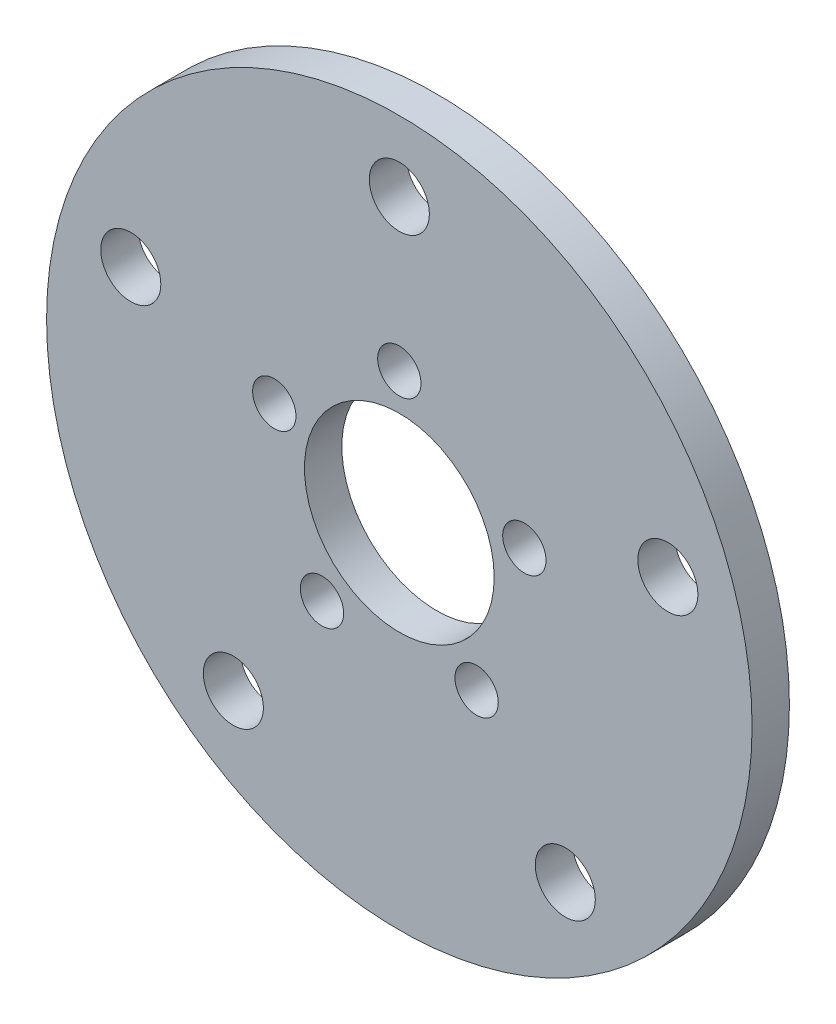
from build123d import *

# Parameters (mm, degrees)
SKETCH1_R           = 29.9847
SKETCH1_R_2         = 8.0645
SKETCH1_R_3         = 1.8415
SKETCH1_R_4         = 2.5527
BOSS_EXTRUDE1_DEPTH = 3.175


with BuildPart() as part:
    # Sketch1 → Boss-Extrude1 (new body)
    with BuildSketch(Plane.XY):
        Circle(SKETCH1_R)
        Circle(SKETCH1_R_2, mode=Mode.SUBTRACT)
        with Locations((0, 11.176)):
            Circle(SKETCH1_R_3, mode=Mode.SUBTRACT)
        with Locations((0, 24.000000006)):
            Circle(SKETCH1_R_4, mode=Mode.SUBTRACT)
        with Locations((10.629007626, 3.453573929)):
            Circle(SKETCH1_R_3, mode=Mode.SUBTRACT)
        with Locations((22.825356397, 7.416407867)):
            Circle(SKETCH1_R_4, mode=Mode.SUBTRACT)
        with Locations((6.56908798, -9.041573929)):
            Circle(SKETCH1_R_3, mode=Mode.SUBTRACT)
        with Locations((14.106846059, -19.41640787)):
            Circle(SKETCH1_R_4, mode=Mode.SUBTRACT)
        with Locations((-6.56908798, -9.041573929)):
            Circle(SKETCH1_R_3, mode=Mode.SUBTRACT)
        with Locations((-14.106846059, -19.41640787)):
            Circle(SKETCH1_R_4, mode=Mode.SUBTRACT)
        with Locations((-10.629007626, 3.453573929)):
            Circle(SKETCH1_R_3, mode=Mode.SUBTRACT)
        with Locations((-22.825356397, 7.416407867)):
            Circle(SKETCH1_R_4, mode=Mode.SUBTRACT)
    extrude(amount=BOSS_EXTRUDE1_DEPTH)


solid = part.part
